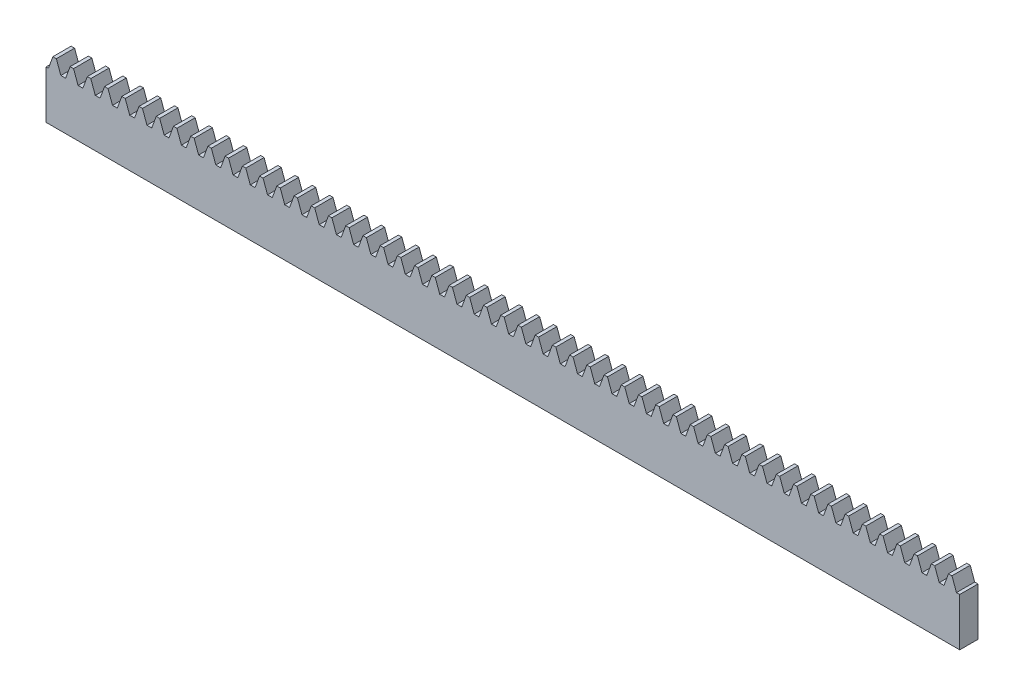
from build123d import *

# Parameters (mm, degrees)
BLANKSKE_W        = 250
BLANKSKE_H        = 16.5
BLANK_DEPTH       = 5
TOOTHCUTSIM_DEPTH = 251.593794815
TEETHCUTS_COUNT   = 54
TEETHCUTS_PITCH   = 4.712388975


with BuildPart() as part:
    # BlankSke → Blank (new body)
    with BuildSketch(Plane.XY):
        with Locations((125, 8.25)):
            Rectangle(BLANKSKE_W, BLANKSKE_H)
    extrude(amount=-BLANK_DEPTH)

    # TooCutSkeSim → ToothCutSim (cut, through all)
    with BuildSketch(Plane.XY):
        Polygon((0.654653055, 13.125), (-0.654653055, 13.125), (-1.892297439, 16.5254), (1.892297439, 16.5254), align=None)
    toothcutsim = extrude(amount=-TOOTHCUTSIM_DEPTH, mode=Mode.SUBTRACT)

    # TeethCuts: ToothCutSim ×54
    with Locations(*[(i * TEETHCUTS_PITCH, 0, 0) for i in range(1, TEETHCUTS_COUNT)]):
        add(toothcutsim, mode=Mode.SUBTRACT)


solid = part.part
